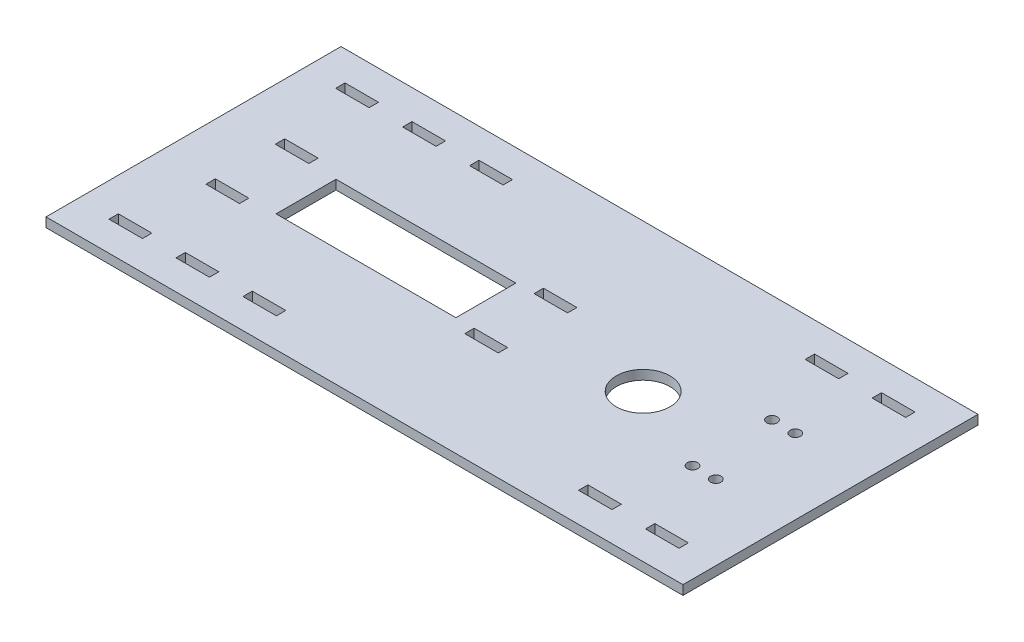
from build123d import *

# Parameters (mm, degrees)
SKETCH1_W               = 215.9
SKETCH1_H               = 100
BOSS_EXTRUDE1_DEPTH     = 3.175
SKETCH3_W               = 11.35
SKETCH3_H               = 3.175
CUT_EXTRUDE2_DEPTH      = 3.175
SKETCH4_W               = 11.35
SKETCH4_H               = 3.175
CUT_EXTRUDE3_DEPTH      = 3.175
SKETCH5_W               = 60.96
SKETCH5_H               = 20.32
CUT_EXTRUDE4_DEPTH      = 1
CUT_EXTRUDE4_DEPTH_BACK = 3.175
SKETCH7_R               = 9.1
CUT_EXTRUDE6_DEPTH      = 3.175
SKETCH8_R               = 1.778
CUT_EXTRUDE7_DEPTH      = 3.175
SKETCH9_W               = 11.35
SKETCH9_H               = 3.175
CUT_EXTRUDE8_DEPTH      = 3.175


with BuildPart() as part:
    # Sketch1 → Boss-Extrude1 (new body)
    with BuildSketch(Plane(origin=(0, 0, 0), x_dir=(1, 0, 0), z_dir=(0, 1, 0))):
        with Locations((-1.255776173, 17.463898917)):
            Rectangle(SKETCH1_W, SKETCH1_H)
    extrude(amount=BOSS_EXTRUDE1_DEPTH)

    # Sketch3 → Cut-Extrude2 (cut)
    with BuildSketch(Plane(origin=(0, 3.175, 0), x_dir=(1, 0, 0), z_dir=(0, 1, 0))):
        with Locations((-92.180776173, 55.876398917)):
            Rectangle(SKETCH3_W, SKETCH3_H)
        with Locations((-46.780776173, 55.876398917)):
            Rectangle(SKETCH3_W, SKETCH3_H)
        with Locations((-69.480776173, 55.876398917)):
            Rectangle(SKETCH3_W, SKETCH3_H)
        with Locations((66.969233827, 55.876398917)):
            Rectangle(SKETCH3_W, SKETCH3_H)
        with Locations((89.669223827, 55.876398917)):
            Rectangle(SKETCH3_W, SKETCH3_H)
    extrude(amount=-CUT_EXTRUDE2_DEPTH, mode=Mode.SUBTRACT)

    # Sketch4 → Cut-Extrude3 (cut)
    with BuildSketch(Plane(origin=(0, 3.175, 0), x_dir=(1, 0, 0), z_dir=(0, 1, 0))):
        with Locations((-92.180776173, -20.948601083)):
            Rectangle(SKETCH4_W, SKETCH4_H)
        with Locations((-69.480776173, -20.948601083)):
            Rectangle(SKETCH4_W, SKETCH4_H)
        with Locations((-46.780776173, -20.948601083)):
            Rectangle(SKETCH4_W, SKETCH4_H)
        with Locations((66.969233827, -20.948601083)):
            Rectangle(SKETCH4_W, SKETCH4_H)
        with Locations((89.669223827, -20.948601083)):
            Rectangle(SKETCH4_W, SKETCH4_H)
    extrude(amount=-CUT_EXTRUDE3_DEPTH, mode=Mode.SUBTRACT)

    # Sketch5 → Cut-Extrude4 (cut, two sides)
    with BuildSketch(Plane(origin=(0, 3.175, 0), x_dir=(1, 0, 0), z_dir=(0, 1, 0))) as cut_extrude4_sk:
        with Locations((-40.625776173, 17.503898917)):
            Rectangle(SKETCH5_W, SKETCH5_H)
    extrude(amount=CUT_EXTRUDE4_DEPTH, mode=Mode.SUBTRACT)
    extrude(cut_extrude4_sk.sketch, amount=-CUT_EXTRUDE4_DEPTH_BACK, mode=Mode.SUBTRACT)

    # Sketch7 → Cut-Extrude6 (cut)
    with BuildSketch(Plane(origin=(0, 3.175, 0), x_dir=(1, 0, 0), z_dir=(0, 1, 0))):
        with Locations((43.194223827, 17.463898917)):
            Circle(SKETCH7_R)
    extrude(amount=-CUT_EXTRUDE6_DEPTH, mode=Mode.SUBTRACT)

    # Sketch8 → Cut-Extrude7 (cut)
    with BuildSketch(Plane(origin=(0, 3.175, 0), x_dir=(1, 0, 0), z_dir=(0, 1, 0))):
        with Locations((73.394823827, 30.938498917)):
            Circle(SKETCH8_R)
        with Locations((81.294223827, 3.989098917)):
            Circle(SKETCH8_R)
        with Locations((73.394823827, 3.989098917)):
            Circle(SKETCH8_R)
        with Locations((81.294223827, 30.938498917)):
            Circle(SKETCH8_R)
    extrude(amount=-CUT_EXTRUDE7_DEPTH, mode=Mode.SUBTRACT)

    # Sketch9 → Cut-Extrude8 (cut)
    with BuildSketch(Plane(origin=(0, 3.175, 0), x_dir=(1, 0, 0), z_dir=(0, 1, 0))):
        with Locations((-86.004776173, 5.756398917)):
            Rectangle(SKETCH9_W, SKETCH9_H)
        with Locations((-86.004776173, 29.251398917)):
            Rectangle(SKETCH9_W, SKETCH9_H)
        with Locations((1.705223827, 5.756398917)):
            Rectangle(SKETCH9_W, SKETCH9_H)
        with Locations((1.705223827, 29.251398917)):
            Rectangle(SKETCH9_W, SKETCH9_H)
    extrude(amount=-CUT_EXTRUDE8_DEPTH, mode=Mode.SUBTRACT)


solid = part.part
